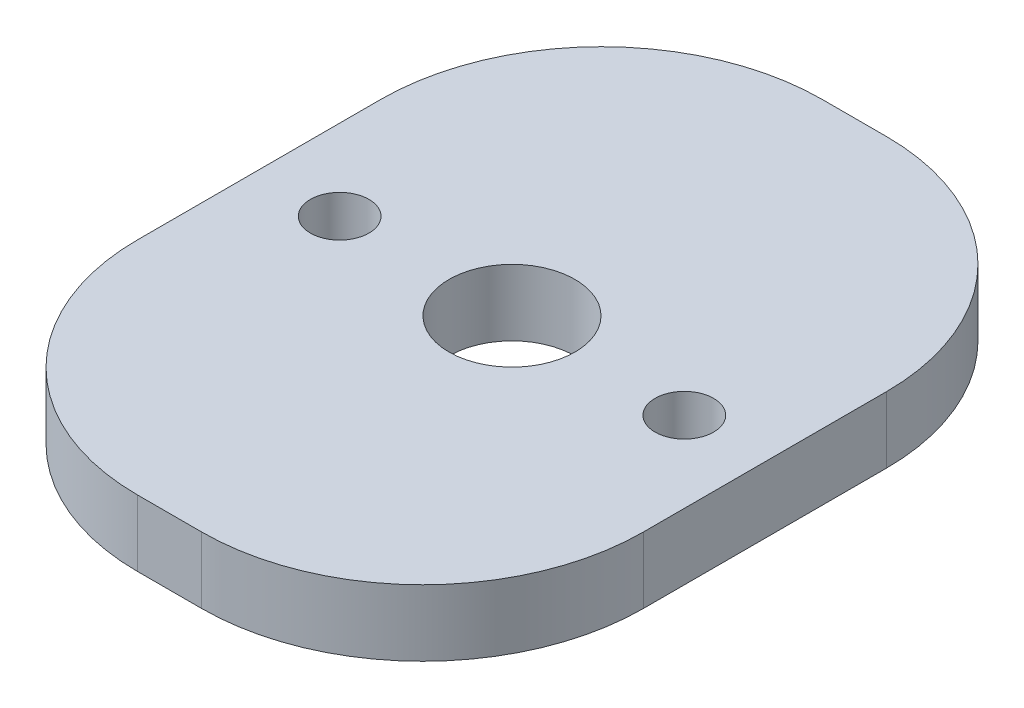
from build123d import *

# Parameters (mm, degrees)
SKETCH1_R           = 1.325
SKETCH1_R_2         = 2.85
BOSS_EXTRUDE1_DEPTH = 3


with BuildPart() as part:
    # Sketch1 → Boss-Extrude1 (new body)
    with BuildSketch(Plane(origin=(0, 0, 0), x_dir=(1, 0, 0), z_dir=(0, 1, 0))):
        with BuildLine():
            Line((-1.45, 15.5), (1.45, 15.5))
            ThreePointArc((1.45, 15.5), (8.521067812, 12.571067812), (11.45, 5.5))
            Line((11.45, 5.5), (11.45, -5.5))
            ThreePointArc((11.45, -5.5), (8.521067812, -12.571067812), (1.45, -15.5))
            Line((1.45, -15.5), (-1.45, -15.5))
            ThreePointArc((-1.45, -15.5), (-8.521067812, -12.571067812), (-11.45, -5.5))
            Line((-11.45, -5.5), (-11.45, 5.5))
            ThreePointArc((-11.45, 5.5), (-8.521067812, 12.571067812), (-1.45, 15.5))
        make_face()
        with Locations((7.8, 0)):
            Circle(SKETCH1_R, mode=Mode.SUBTRACT)
        with Locations((-7.8, 0)):
            Circle(SKETCH1_R, mode=Mode.SUBTRACT)
        Circle(SKETCH1_R_2, mode=Mode.SUBTRACT)
    extrude(amount=BOSS_EXTRUDE1_DEPTH)


solid = part.part
